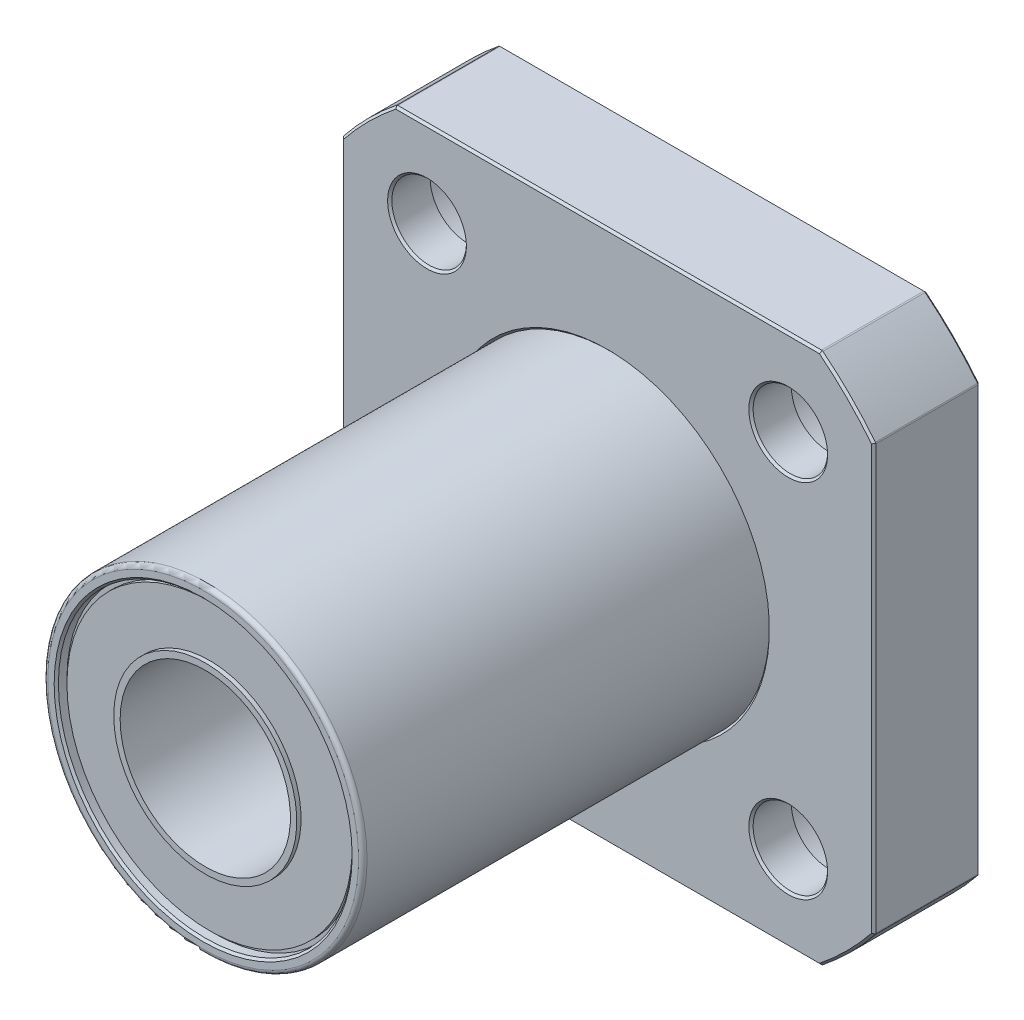
from build123d import *

# Parameters (mm, degrees)
SKETCH_1_W          = 25
SKETCH_1_H          = 25
SKETCH_1_R          = 7.5
EXTRUDE_1_DEPTH     = 5
SKETCH_3_OUTSIDE_W  = 34.142
SKETCH_3_OUTSIDE_H  = 34.142
SKETCH_3_OUTSIDE_R  = 16
CUT_EXTRUDE_2_DEPTH = 5
SKETCH_5_R          = 1.75
CUT_EXTRUDE_3_DEPTH = 5
SKETCH_5_3_R        = 3
SKETCH_5_3_R_2      = 1.75
CUT_EXTRUDE_4_DEPTH = 3.1
CHAMFER_1_SIZE      = 0.1
SKETCH_7_R          = 7.5
SKETCH_7_R_2        = 6.9
EXTRUDE_2_DEPTH     = 24
FILLET_1_R          = 0.2
CHAMFER_2_SIZE      = 0.1
FILLET_2_R          = 0.1


with BuildPart() as part:
    # Sketch 1 → Extrude 1 (new body)
    with BuildSketch(Plane.XY):
        Rectangle(SKETCH_1_W, SKETCH_1_H)
        Circle(SKETCH_1_R, mode=Mode.SUBTRACT)
    extrude(amount=EXTRUDE_1_DEPTH)

    # Sketch 3 outside → Cut-Extrude 2 (cut)
    with BuildSketch(Plane.XY.offset(5)):
        Rectangle(SKETCH_3_OUTSIDE_W, SKETCH_3_OUTSIDE_H)
        Circle(SKETCH_3_OUTSIDE_R, mode=Mode.SUBTRACT)
    extrude(amount=-CUT_EXTRUDE_2_DEPTH, mode=Mode.SUBTRACT)

    # Sketch 5 → Cut-Extrude 3 (cut)
    with BuildSketch(Plane.XY):
        with Locations(Location((-8.485281374, 8.485281374, 0), (0, 0, 180))):  # turned: the seam where the file's is
            Circle(SKETCH_5_R)
        with Locations(Location((-8.485281374, -8.485281374, 0), (0, 0, 180))):  # turned: the seam where the file's is
            Circle(SKETCH_5_R)
        with Locations(Location((8.485281374, -8.485281374, 0), (0, 0, 180))):  # turned: the seam where the file's is
            Circle(SKETCH_5_R)
        with Locations(Location((8.485281374, 8.485281374, 0), (0, 0, 180))):  # turned: the seam where the file's is
            Circle(SKETCH_5_R)
    extrude(amount=CUT_EXTRUDE_3_DEPTH, mode=Mode.SUBTRACT)

    # Sketch 5_3 → Cut-Extrude 4 (cut)
    with BuildSketch(Plane.XY):
        with Locations((-8.485281374, 8.485281374)):
            Circle(SKETCH_5_3_R)
        with Locations(Location((-8.485281374, 8.485281374, 0), (0, 0, 180))):  # turned: the seam where the file's is
            Circle(SKETCH_5_3_R_2, mode=Mode.SUBTRACT)
        with Locations(Location((8.485281374, 8.485281374, 0), (0, 0, 180))):  # turned: the seam where the file's is
            Circle(SKETCH_5_3_R)
        with Locations(Location((8.485281374, 8.485281374, 0), (0, 0, 180))):  # turned: the seam where the file's is
            Circle(SKETCH_5_3_R_2, mode=Mode.SUBTRACT)
        with Locations((8.485281374, -8.485281374)):
            Circle(SKETCH_5_3_R)
        with Locations(Location((8.485281374, -8.485281374, 0), (0, 0, 180))):  # turned: the seam where the file's is
            Circle(SKETCH_5_3_R_2, mode=Mode.SUBTRACT)
        with Locations(Location((-8.485281374, -8.485281374, 0), (0, 0, 180))):  # turned: the seam where the file's is
            Circle(SKETCH_5_3_R)
        with Locations(Location((-8.485281374, -8.485281374, 0), (0, 0, 180))):  # turned: the seam where the file's is
            Circle(SKETCH_5_3_R_2, mode=Mode.SUBTRACT)
    extrude(amount=CUT_EXTRUDE_4_DEPTH, mode=Mode.SUBTRACT)

    # Chamfer 1
    chamfer_1_edges = [part.edges().sort_by_distance(p)[0] for p in [
        (11.485281374, 8.485281374, 0),
        (-11.485281374, 8.485281374, 0),
        (-7.5, 0, 0),
        (-7.5, 0, 5),
        (0, -12.5, 0),
        (0, -12.5, 5),
        (-12.5, 0, 0),
        (-12.5, 0, 5),
        (0, 12.5, 0),
        (0, 12.5, 5),
        (12.5, 0, 0),
        (12.5, 0, 5),
        (11.313708499, -11.313708499, 5),
        (11.313708499, 11.313708499, 5),
        (-11.313708499, 11.313708499, 5),
        (-11.313708499, -11.313708499, 5),
        (11.313708499, 11.313708499, 0),
        (-11.313708499, 11.313708499, 0),
        (11.313708499, -11.313708499, 0),
        (-11.313708499, -11.313708499, 0),
        (10.235281374, 8.485281374, 5),
        (10.235281374, -8.485281374, 5),
        (-6.735281374, -8.485281374, 5),
        (-6.735281374, 8.485281374, 5),
        (-5.485281374, -8.485281374, 0),
        (5.485281374, -8.485281374, 0),
    ]]
    chamfer(chamfer_1_edges, length=CHAMFER_1_SIZE)

    # Sketch 7 → Extrude 2 (add)
    with BuildSketch(Plane(origin=(0, 0, 0), x_dir=(-1, 0, 0), z_dir=(0, 0, -1))):
        Circle(SKETCH_7_R)
        Circle(SKETCH_7_R_2, mode=Mode.SUBTRACT)
    extrude(amount=-EXTRUDE_2_DEPTH)

    # Fillet 1
    fillet_1_edges = [part.edges().sort_by_distance(p)[0] for p in [
        (7.5, 0, 24),
    ]]
    fillet(fillet_1_edges, radius=FILLET_1_R)

    # Chamfer 2
    chamfer_2_edges = [part.edges().sort_by_distance(p)[0] for p in [
        (6.9, 0, 24),
    ]]
    chamfer(chamfer_2_edges, length=CHAMFER_2_SIZE)

    # Sketch 8 → Revolve 1 (revolve)
    with BuildSketch(Plane(origin=(0, 0, 0), x_dir=(0, 0, -1), z_dir=(1, 0, 0)), mode=Mode.PRIVATE) as revolve_1_sk:
        Polygon((-23.5, 6.9), (-0.4, 6.9), (-0.4, 6.7), (-0.2, 6.7), (-0.2, 4.3), (0, 4.3), (0, 4), (-23.9, 4), (-23.9, 4.3), (-23.7, 4.3), (-23.7, 6.7), (-23.5, 6.7), align=None)
    revolve(revolve_1_sk.sketch.rotate(Axis((0, 0, 0), (0, 0, 1)), 90), axis=Axis((0, 0, 0), (0, 0, 1)))  # turned: the seam where the file's is

    # Fillet 2
    fillet_2_edges = [part.edges().sort_by_distance(p)[0] for p in [
        (-9.987492178, 12.5, 2.5),
        (-12.5, 9.987492178, 2.5),
        (-12.5, -9.987492178, 2.5),
        (-9.987492178, -12.5, 2.5),
        (9.987492178, -12.5, 2.5),
        (12.5, -9.987492178, 2.5),
        (12.5, 9.987492178, 2.5),
        (9.987492178, 12.5, 2.5),
    ]]
    fillet(fillet_2_edges, radius=FILLET_2_R)


solid = part.part
